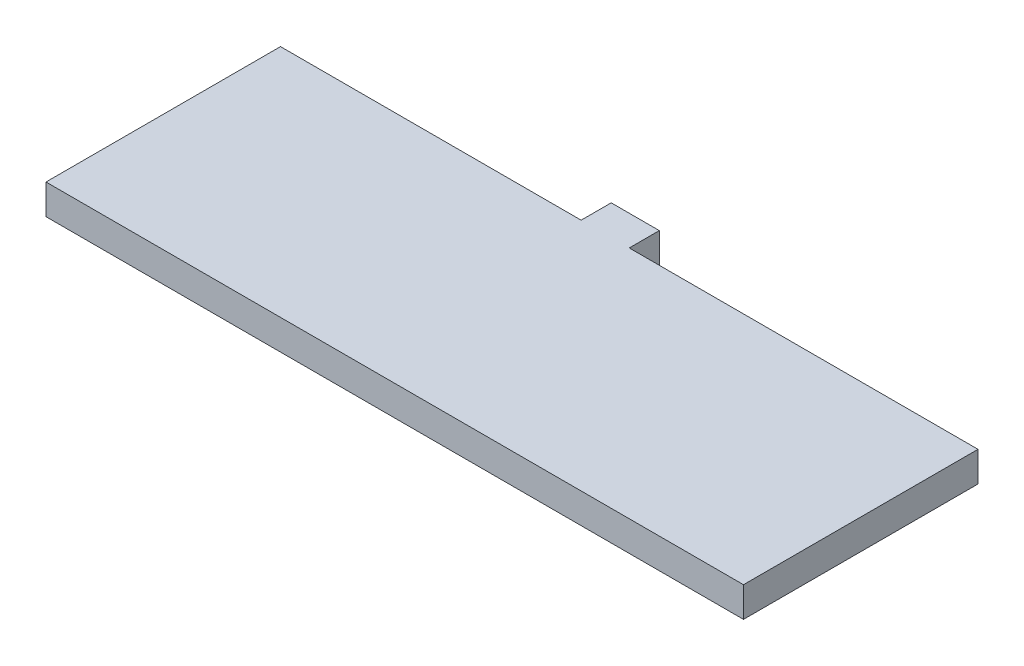
from build123d import *

# Parameters (mm, degrees)
SKETCH2_W           = 73.66
SKETCH2_H           = 24.765
SKETCH2_W_2         = 5.08
SKETCH2_H_2         = 3.175
BOSS_EXTRUDE1_DEPTH = 3.175


with BuildPart() as part:
    # Sketch2 → Boss-Extrude1 (new body)
    with BuildSketch(Plane(origin=(0, 0, 0), x_dir=(1, 0, 0), z_dir=(0, 1, 0))):
        with Locations((0, -12.3825)):
            Rectangle(SKETCH2_W, SKETCH2_H)
        with Locations((-2.54, 1.5875)):
            Rectangle(SKETCH2_W_2, SKETCH2_H_2)
    extrude(amount=BOSS_EXTRUDE1_DEPTH)


solid = part.part
